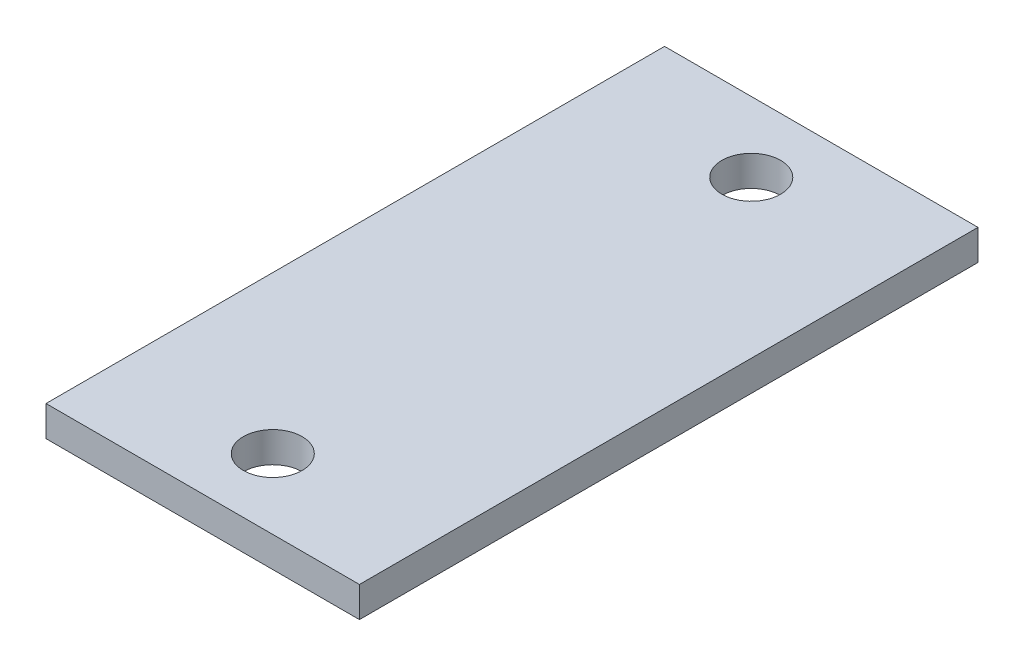
from build123d import *

# Parameters (mm, degrees)
SKETCH1_W    = 50.8
SKETCH1_H    = 100.25
SKETCH1_R    = 4.7625
HAMMER_DEPTH = 4.93522


with BuildPart() as part:
    # Sketch1 → Hammer (new body)
    with BuildSketch(Plane(origin=(0, 0, 0), x_dir=(1, 0, 0), z_dir=(0, 1, 0))):
        with Locations((25.4, 50.125)):
            Rectangle(SKETCH1_W, SKETCH1_H)
        with Locations((25.4, 11.35)):
            Circle(SKETCH1_R, mode=Mode.SUBTRACT)
        with Locations((25.4, 88.9)):
            Circle(SKETCH1_R, mode=Mode.SUBTRACT)
    extrude(amount=HAMMER_DEPTH)


solid = part.part
